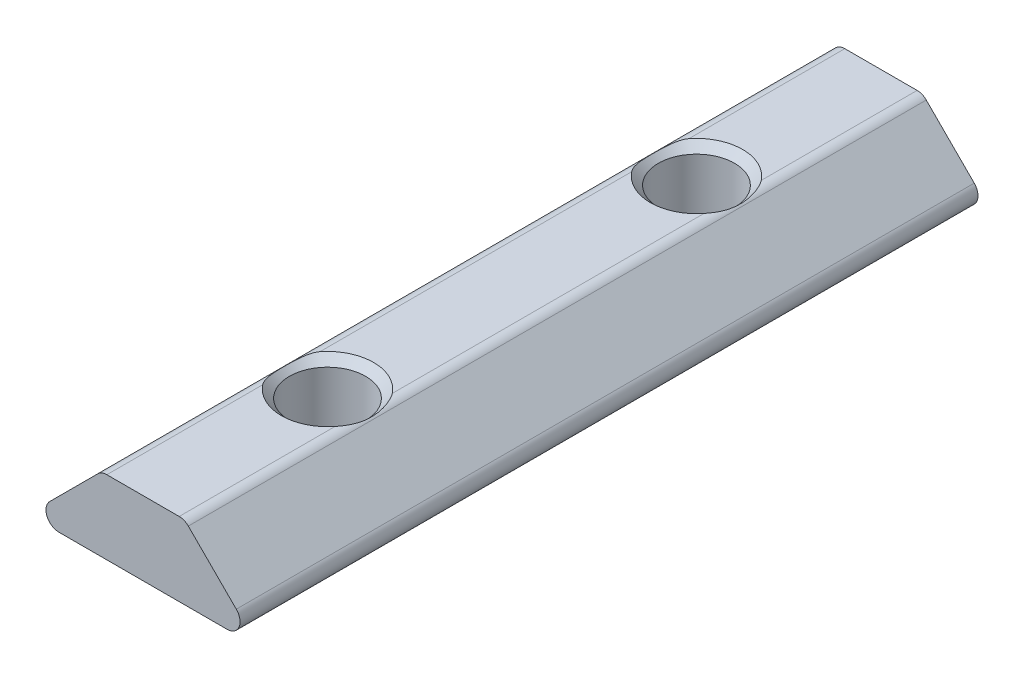
from build123d import *

# Parameters (mm, degrees)
BOSS_EXTRUDE1_DEPTH      = 20
BOSS_EXTRUDE1_DEPTH_BACK = 20


with BuildPart() as part:
    # Sketch1 → Boss-Extrude1 (new, two sides: drawn at the far end of the back side and taken through both)
    with BuildSketch(Plane.XY.offset(-BOSS_EXTRUDE1_DEPTH_BACK)):
        with BuildLine():
            Line((-4.560050506, 0), (4.560050506, 0))
            ThreePointArc((4.560050506, 0), (5.206766179, 0.432121597), (5.055025253, 1.194974747))
            Line((5.055025253, 1.194974747), (2.455025253, 3.794974747))
            ThreePointArc((2.455025253, 3.794974747), (2.227928909, 3.946715673), (1.960050506, 4))
            Line((1.960050506, 4), (-1.960050506, 4))
            ThreePointArc((-1.960050506, 4), (-2.227928909, 3.946715673), (-2.455025253, 3.794974747))
            Line((-2.455025253, 3.794974747), (-5.055025253, 1.194974747))
            ThreePointArc((-5.055025253, 1.194974747), (-5.206766179, 0.432121597), (-4.560050506, 0))
        make_face()
    extrude(amount=BOSS_EXTRUDE1_DEPTH + BOSS_EXTRUDE1_DEPTH_BACK)

    # Sketch2 → Cut-Revolve1 (revolve, cut)
    with BuildSketch(Plane(origin=(0, 0, 0), x_dir=(0, 0, -1), z_dir=(1, 0, 0))):
        Polygon((-10, 4), (-7.5, 4), (-7.933, 3.567), (-7.933, 0.433), (-7.5, 0), (-10, 0), align=None)
    revolve(axis=Axis((0, 0, 10), (0, 1, 0)), mode=Mode.SUBTRACT)

    # Sketch3 → Cut-Revolve2 (revolve, cut)
    with BuildSketch(Plane(origin=(0, 0, 0), x_dir=(0, 0, -1), z_dir=(1, 0, 0))):
        Polygon((10, 4), (12.5, 4), (12.067, 3.567), (12.067, 0.433), (12.5, 0), (10, 0), align=None)
    revolve(axis=Axis((0, 0, -10), (0, 1, 0)), mode=Mode.SUBTRACT)


solid = part.part
